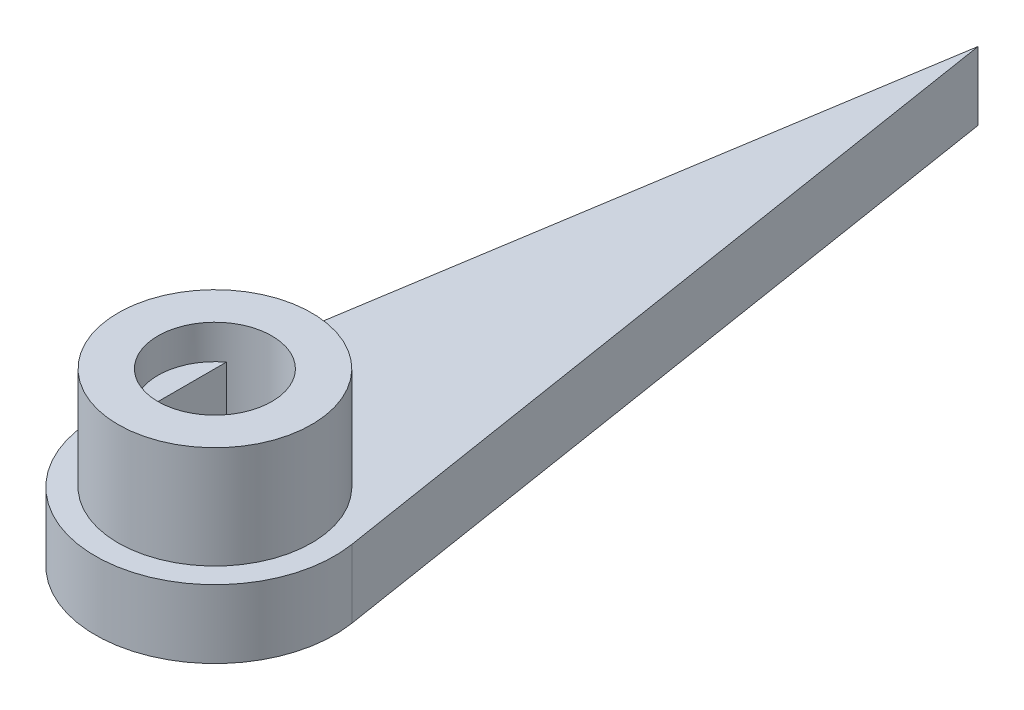
from build123d import *

# Parameters (mm, degrees)
SKETCH5_R           = 4.25
BOSS_EXTRUDE3_DEPTH = 7.5
SKETCH7_R           = 2.5
CUT_EXTRUDE2_DEPTH  = 1.5
CUT_EXTRUDE3_DEPTH  = 6
SKETCH9_R           = 5.25
BOSS_EXTRUDE4_DEPTH = 3


with BuildPart() as part:
    # Sketch5 → Boss-Extrude3 (new body)
    with BuildSketch(Plane(origin=(0, 0, 0), x_dir=(1, 0, 0), z_dir=(0, 1, 0))):
        Circle(SKETCH5_R)
    extrude(amount=BOSS_EXTRUDE3_DEPTH)

    # Sketch7 → Cut-Extrude2 (cut)
    with BuildSketch(Plane(origin=(0, 7.5, 0), x_dir=(1, 0, 0), z_dir=(0, 1, 0))):
        Circle(SKETCH7_R)
    extrude(amount=-CUT_EXTRUDE2_DEPTH, mode=Mode.SUBTRACT)

    # Sketch8 → Cut-Extrude3 (cut)
    with BuildSketch(Plane(origin=(0, 6, 0), x_dir=(1, 0, 0), z_dir=(0, 1, 0))):
        with BuildLine():
            Line((-1.5, -2), (-1.5, 2))
            ThreePointArc((-1.5, 2), (0, 2.5), (1.5, 2))
            Line((1.5, 2), (1.5, -2))
            ThreePointArc((1.5, -2), (0, -2.5), (-1.5, -2))
        make_face()
    extrude(amount=-CUT_EXTRUDE3_DEPTH, mode=Mode.SUBTRACT)

    # Sketch9 → Boss-Extrude4 (add)
    with BuildSketch(Plane(origin=(0, 0, 0), x_dir=(1, 0, 0), z_dir=(0, 1, 0))):
        with BuildLine():
            Line((0, 33.5), (-5.185129123, 0.822761194))
            ThreePointArc((-5.185129123, 0.822761194), (0, 5.25), (5.185129123, 0.822761194))
            Line((5.185129123, 0.822761194), (0, 33.5))
        make_face()
        Circle(SKETCH9_R)
        with BuildLine():
            ThreePointArc((1.5, 2), (0, 2.5), (-1.5, 2))
            Line((-1.5, 2), (-1.5, -2))
            ThreePointArc((-1.5, -2), (0, -2.5), (1.5, -2))
            Line((1.5, -2), (1.5, 2))
        make_face(mode=Mode.SUBTRACT)
    extrude(amount=BOSS_EXTRUDE4_DEPTH)


solid = part.part
